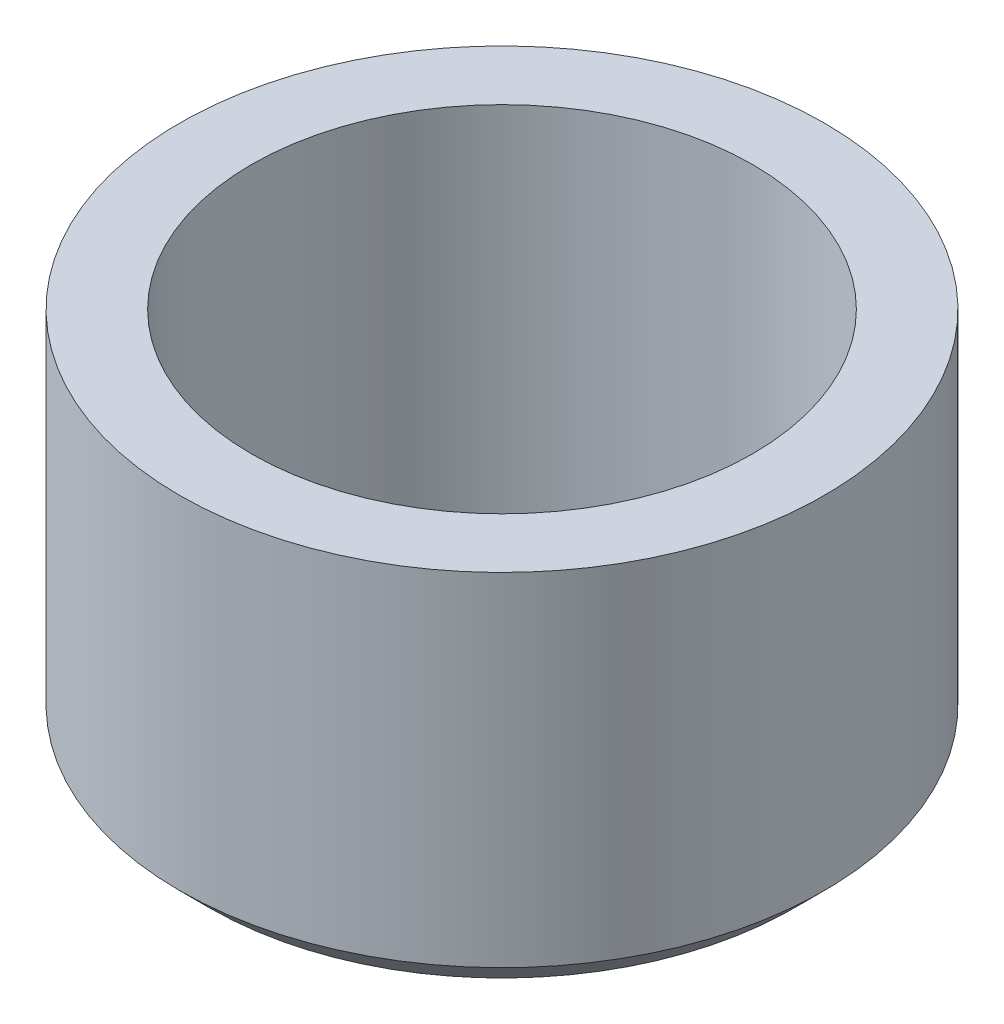
from build123d import *

# Parameters (mm, degrees)
SKETCH1_W     = 1.175
SKETCH1_H     = 6.1
CHAMFER1_SIZE = 0.5


with BuildPart() as part:
    # Sketch1 → Revolve1 (revolve)
    with BuildSketch(Plane.XY):
        with Locations((-4.6875, 3.05)):
            Rectangle(SKETCH1_W, SKETCH1_H)
    revolve(axis=Axis((0, 36.057377049, 0), (0, -1, 0)))

    # Chamfer1
    chamfer1_edges = [part.edges().sort_by_distance(p)[0] for p in [
        (5.275, 0, 0),
    ]]
    chamfer(chamfer1_edges, length=CHAMFER1_SIZE)


solid = part.part
